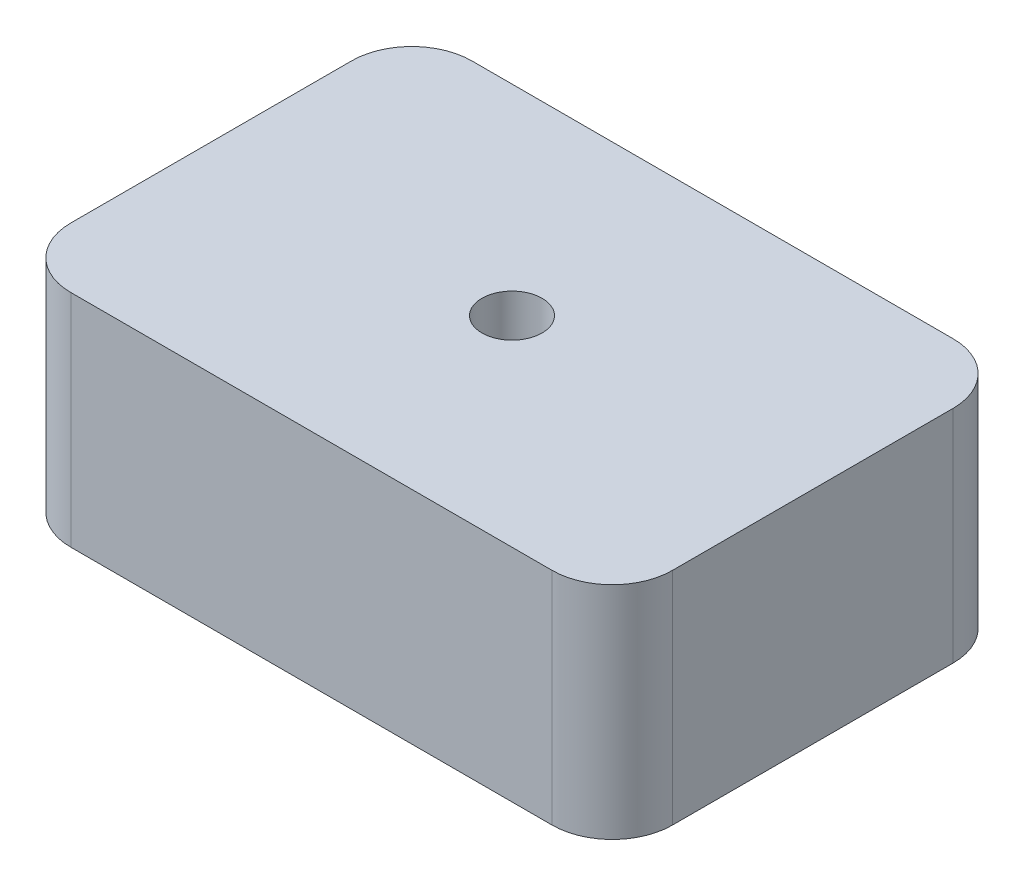
from build123d import *

# Parameters (mm, degrees)
SKETCH1_W           = 150
SKETCH1_H           = 100
SKETCH1_R           = 7.5
BOSS_EXTRUDE1_DEPTH = 55
FILLET1_R           = 15


with BuildPart() as part:
    # Sketch1 → Boss-Extrude1 (new body)
    with BuildSketch(Plane(origin=(0, 0, 0), x_dir=(1, 0, 0), z_dir=(0, 1, 0))):
        Rectangle(SKETCH1_W, SKETCH1_H)
        Circle(SKETCH1_R, mode=Mode.SUBTRACT)
    extrude(amount=BOSS_EXTRUDE1_DEPTH)

    # Fillet1
    fillet1_edges = [part.edges().sort_by_distance(p)[0] for p in [
        (75, 27.5, 50),
        (-75, 27.5, 50),
        (-75, 27.5, -50),
        (75, 27.5, -50),
    ]]
    fillet(fillet1_edges, radius=FILLET1_R)


solid = part.part
